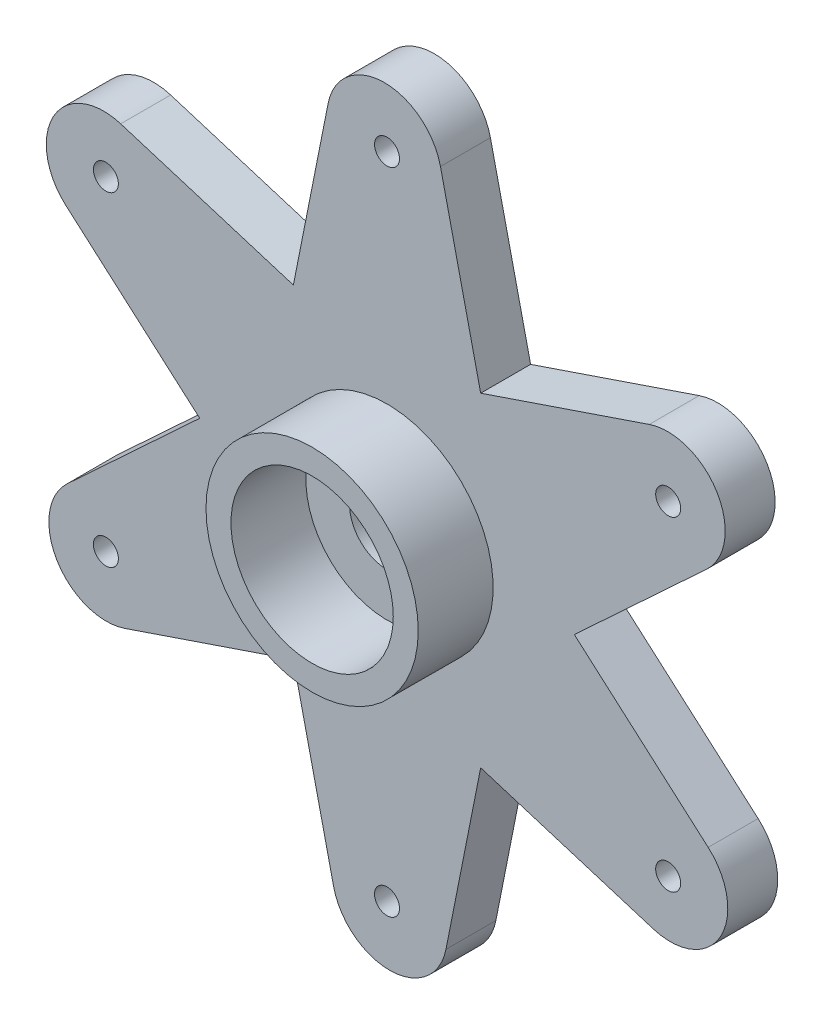
from build123d import *

# Parameters (mm, degrees)
ESBO_O1_R                = 1.5
RESSALTO_EXTRUS_O1_DEPTH = 1
ESBO_O2_R                = 4.25
ESBO_O2_R_2              = 3.25
RESSALTO_EXTRUS_O2_DEPTH = 3
ESBO_O3_R                = 0.5
CORTE_EXTRUS_O1_DEPTH    = 2


with BuildPart() as part:
    # Esboço1 → Ressalto-extrusão1 (new body, symmetric)
    with BuildSketch(Plane.XY):
        with BuildLine():
            Line((3.75, 6.495190528), (2.140193877, 13.55121581))
            ThreePointArc((2.140193877, 13.55121581), (-0.135352736, 15.340099778), (-2.359806123, 13.488067011))
            Line((-2.359806123, 13.488067011), (-3.75, 6.495190528))
            Line((-3.75, 6.495190528), (-10.665600205, 8.629070172))
            ThreePointArc((-10.665600205, 8.629070172), (-13.352592472, 7.552830981), (-12.86091174, 4.700381455))
            Line((-12.86091174, 4.700381455), (-7.5, 0))
            Line((-7.5, 0), (-12.805794082, -4.922145638))
            ThreePointArc((-12.805794082, -4.922145638), (-13.217239736, -7.787268797), (-10.501105618, -8.787685556))
            Line((-10.501105618, -8.787685556), (-3.75, -6.495190528))
            Line((-3.75, -6.495190528), (-2.140193877, -13.55121581))
            ThreePointArc((-2.140193877, -13.55121581), (0.135352736, -15.340099778), (2.359806123, -13.488067011))
            Line((2.359806123, -13.488067011), (3.75, -6.495190528))
            Line((3.75, -6.495190528), (10.665600205, -8.629070172))
            ThreePointArc((10.665600205, -8.629070172), (13.352592472, -7.552830981), (12.86091174, -4.700381455))
            Line((12.86091174, -4.700381455), (7.5, 0))
            Line((7.5, 0), (12.805794082, 4.922145638))
            ThreePointArc((12.805794082, 4.922145638), (13.217239736, 7.787268797), (10.501105618, 8.787685556))
            Line((10.501105618, 8.787685556), (3.75, 6.495190528))
        make_face()
        Circle(ESBO_O1_R, mode=Mode.SUBTRACT)
    extrude(amount=RESSALTO_EXTRUS_O1_DEPTH, both=True)

    # Esboço2 → Ressalto-extrusão2 (add)
    with BuildSketch(Plane.XY.offset(1)):
        Circle(ESBO_O2_R)
        Circle(ESBO_O2_R_2, mode=Mode.SUBTRACT)
    extrude(amount=RESSALTO_EXTRUS_O2_DEPTH)

    # Esboço3 → Corte-extrusão1 (cut)
    with BuildSketch(Plane.XY.offset(1)):
        with Locations((0, 13)):
            Circle(ESBO_O3_R)
        with Locations((11.258330249, 6.5)):
            Circle(ESBO_O3_R)
        with Locations((11.258330249, -6.5)):
            Circle(ESBO_O3_R)
        with Locations((0, -13)):
            Circle(ESBO_O3_R)
        with Locations((-11.258330249, -6.5)):
            Circle(ESBO_O3_R)
        with Locations((-11.258330249, 6.5)):
            Circle(ESBO_O3_R)
    extrude(amount=-CORTE_EXTRUS_O1_DEPTH, mode=Mode.SUBTRACT)


solid = part.part
